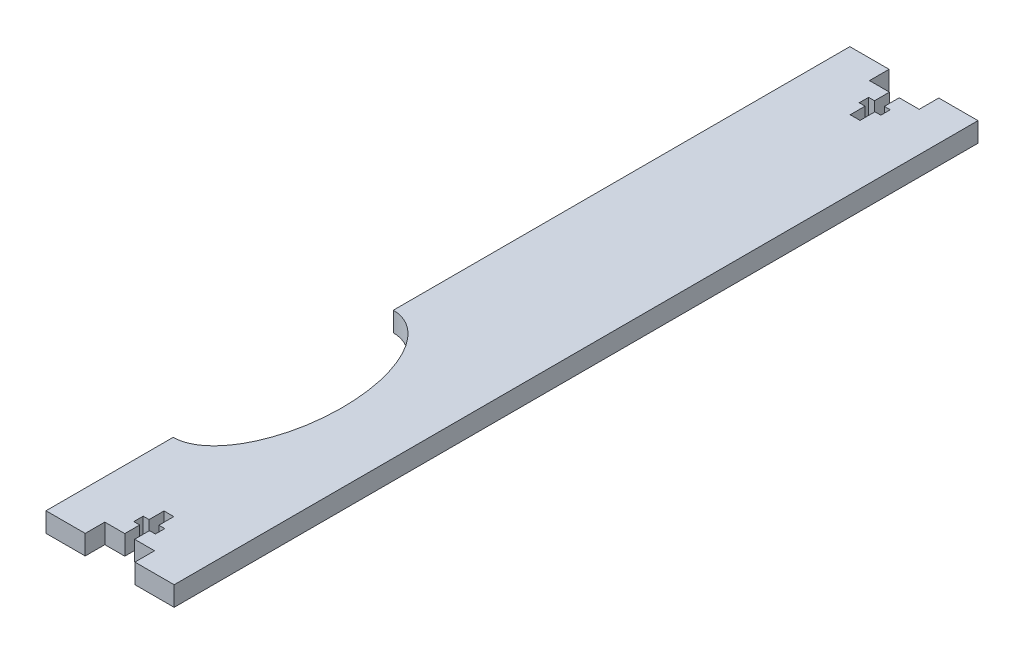
from build123d import *

# Parameters (mm, degrees)
SCHIZZO1_W                   = 32.68
SCHIZZO1_H                   = 205
ESTRUSIONE_ESTRUSIONE1_DEPTH = 5
SCHIZZO3_W                   = 12.68
SCHIZZO3_H                   = 5
TAGLIO_ESTRUSIONE1_DEPTH     = 6
TAGLIO_ESTRUSIONE2_DEPTH     = 6
SCHIZZO5_RX                  = 28.071854537
SCHIZZO5_RY                  = 15
TAGLIO_ESTRUSIONE3_DEPTH     = 6


with BuildPart() as part:
    # Schizzo1 → Estrusione-Estrusione1 (new body)
    with BuildSketch(Plane(origin=(0, 0, 0), x_dir=(1, 0, 0), z_dir=(0, 1, 0))):
        Rectangle(SCHIZZO1_W, SCHIZZO1_H)
    extrude(amount=ESTRUSIONE_ESTRUSIONE1_DEPTH)

    # Schizzo3 → Taglio-Estrusione1 (cut, through all)
    with BuildSketch(Plane(origin=(0, 0, 0), x_dir=(1, 0, 0), z_dir=(0, 1, 0))):
        with Locations((0, 100)):
            Rectangle(SCHIZZO3_W, SCHIZZO3_H)
        with Locations((0, -100)):
            Rectangle(SCHIZZO3_W, SCHIZZO3_H)
    extrude(amount=TAGLIO_ESTRUSIONE1_DEPTH, mode=Mode.SUBTRACT)

    # Schizzo4 → Taglio-Estrusione2 (cut, through all)
    with BuildSketch(Plane(origin=(0, 0, 0), x_dir=(1, 0, 0), z_dir=(0, 1, 0))):
        Polygon((-1.25, 87.5), (-1.25, 91.3), (-2.75, 91.3), (-2.75, 93.7), (-1.25, 93.7), (-1.25, 97.5), (1.25, 97.5), (1.25, 93.7), (2.75, 93.7), (2.75, 91.3), (1.25, 91.3), (1.25, 87.5), align=None)
        Polygon((2.75, -91.3), (1.25, -91.3), (1.25, -87.5), (-1.25, -87.5), (-1.25, -91.3), (-2.75, -91.3), (-2.75, -93.7), (-1.25, -93.7), (-1.25, -97.5), (1.25, -97.5), (1.25, -93.7), (2.75, -93.7), align=None)
    extrude(amount=TAGLIO_ESTRUSIONE2_DEPTH, mode=Mode.SUBTRACT)

    # Schizzo5 → Taglio-Estrusione3 (cut, through all)
    with BuildSketch(Plane(origin=(0, 0, 0), x_dir=(1, 0, 0), z_dir=(0, 1, 0))):
        with Locations(Location((-16.34, -42), (0, 0, 90))):
            Ellipse(SCHIZZO5_RX, SCHIZZO5_RY)
    extrude(amount=TAGLIO_ESTRUSIONE3_DEPTH, mode=Mode.SUBTRACT)


solid = part.part
